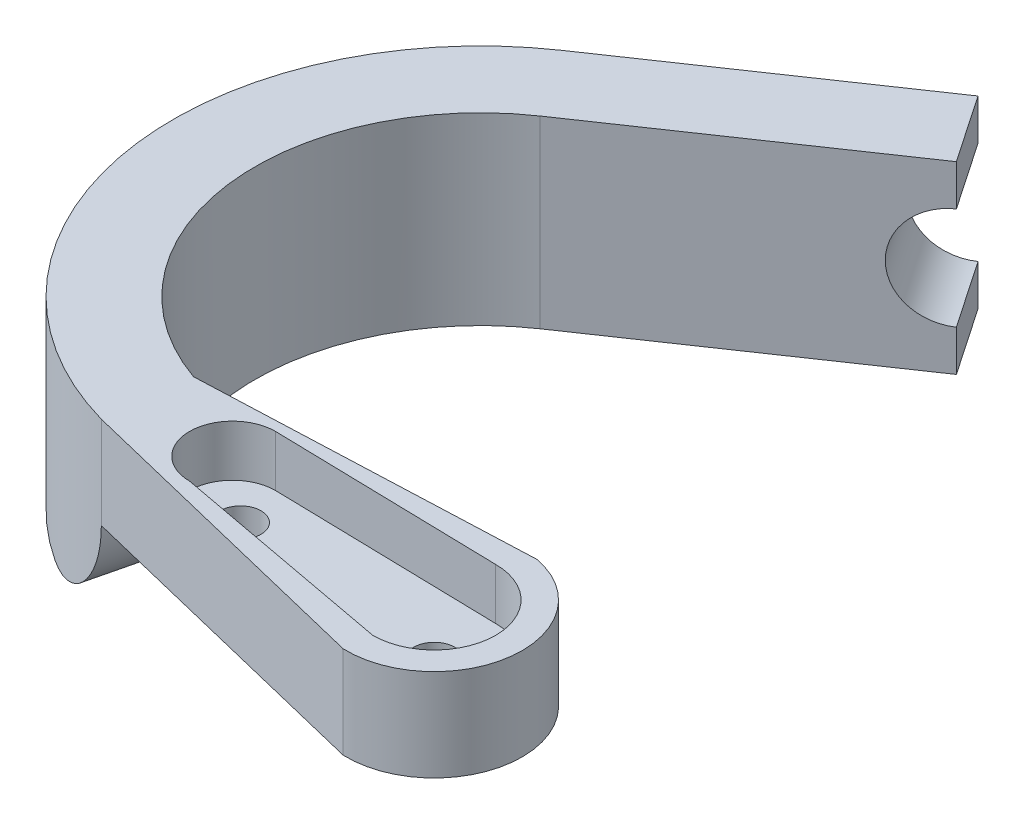
from build123d import *

# Parameters (mm, degrees)
SKETCH_1_R          = 1
EXTRUDE_2_DEPTH     = 9
SKETCH_4_R          = 1
CUT_EXTRUDE_3_DEPTH = 2.5
SKETCH_5_R          = 2.5
CUT_EXTRUDE_4_DEPTH = 5
CUT_EXTRUDE_5_DEPTH = 10


with BuildPart() as part:
    # 草图1 → 凸台-拉伸2 (new body)
    with BuildSketch(Plane(origin=(0, 0, 0), x_dir=(1, 0, 0), z_dir=(0, 1, 0))):
        with BuildLine():
            Line((3.663143512, 20.638777874), (-8.440521732, 12.399902939))
            ThreePointArc((-8.440521732, 12.399902939), (-14.805433948, -2.408137375), (-4.07565223, -14.435686991))
            Line((-4.07565223, -14.435686991), (-3.023376015, -14.692147477))
            Line((-3.023376015, -14.692147477), (11.540736309, -18.241709146))
            ThreePointArc((11.540736309, -18.241709146), (15.964213302, -14.422684135), (12.48297659, -9.728742113))
            Line((12.48297659, -9.728742113), (-3.617537803, -10.389704275))
            ThreePointArc((-3.617537803, -10.389704275), (-10.906788746, -1.440310357), (-6.190548031, 9.094484579))
            Line((-6.190548031, 9.094484579), (5.913117212, 17.333359514))
            Line((5.913117212, 17.333359514), (3.663143512, 20.638777874))
        make_face()
        with Locations(Location((1.196028789, -12.910534794, 0), (0, 0, 270))):
            Circle(SKETCH_1_R, mode=Mode.SUBTRACT)
        with Locations(Location((11.696028789, -13.950268893, 0), (0, 0, 270))):
            Circle(SKETCH_1_R, mode=Mode.SUBTRACT)
    extrude(amount=EXTRUDE_2_DEPTH)

    # 草图4 → 切除-拉伸3 (cut)
    with BuildSketch(Plane(origin=(0, 9, 0), x_dir=(1, 0, 0), z_dir=(0, 1, 0))):
        with BuildLine():
            ThreePointArc((11.696028789, -16.950268893), (14.696028789, -13.950268893), (11.696028789, -10.950268893))
            Line((11.696028789, -10.950268893), (0.791673154, -10.701877185))
            Line((0.791673154, -10.701877185), (0.696028789, -10.69969849))
            ThreePointArc((0.696028789, -10.69969849), (-1.404446611, -12.80017389), (0.696028789, -14.90064929))
            Line((0.696028789, -14.90064929), (11.696028789, -16.950268893))
        make_face()
        with Locations(Location((1.196028789, -12.910534794, 0), (0, 0, 270))):
            Circle(SKETCH_4_R, mode=Mode.SUBTRACT)
        with Locations(Location((11.696028789, -13.950268893, 0), (0, 0, 270))):
            Circle(SKETCH_4_R, mode=Mode.SUBTRACT)
    extrude(amount=-CUT_EXTRUDE_3_DEPTH, mode=Mode.SUBTRACT)

    # 草图5 → 切除-拉伸4 (cut)
    with BuildSketch(Plane(origin=(-8.440521732, 0, -12.399902939), x_dir=(-0.8266601959267582, 0, 0.5627014487899723), z_dir=(-0.5627014487899723, 0, -0.8266601959267582))):
        with Locations((-14.641645144, 4.5)):
            Circle(SKETCH_5_R)
    extrude(amount=-CUT_EXTRUDE_4_DEPTH, mode=Mode.SUBTRACT)

    # 草图6 → 切除-拉伸5 (cut)
    with BuildSketch(Plane(origin=(-3.549514122, 0, 14.563917234), x_dir=(0.9715611869561729, 0, 0.23678863993087312), z_dir=(-0.23678863993087312, 0, 0.9715611869561729))):
        with BuildLine():
            Line((-0.541538829, 4.5), (18.960921895, 4.5))
            Line((18.960921895, 4.5), (18.960921895, 0))
            Line((18.960921895, 0), (-0.541538829, 0))
            Line((-0.541538829, 0), (-5.041538829, 0))
            ThreePointArc((-5.041538829, 0), (-1.859558314, 1.318019485), (-0.541538829, 4.5))
        make_face()
    extrude(amount=-CUT_EXTRUDE_5_DEPTH, mode=Mode.SUBTRACT)


solid = part.part
